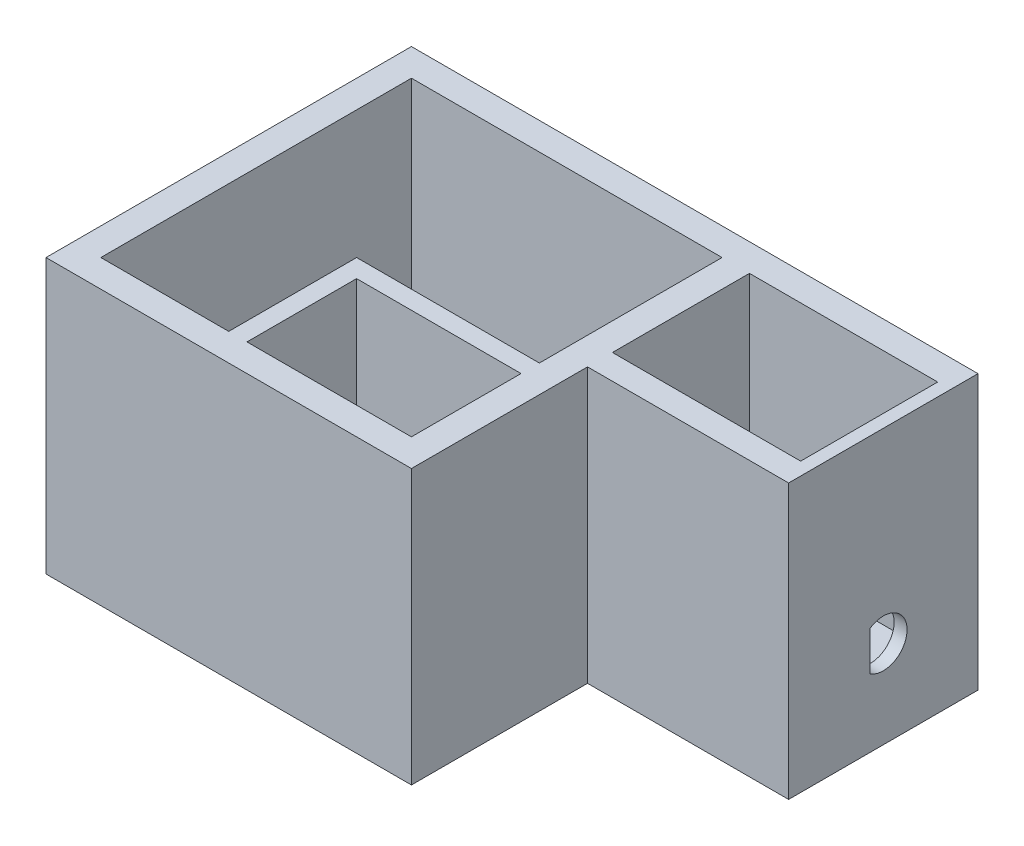
from build123d import *

# Parameters (mm, degrees)
CROQUIS2_W                 = 100
CROQUIS2_H                 = 100
SALIENTE_EXTRUIR1_DEPTH    = 75
CROQUIS3_W                 = 85
CROQUIS3_H                 = 85
CORTAR_EXTRUIR1_DEPTH      = 65
CROQUIS4_W                 = 50
CROQUIS4_H                 = 35
SALIENTE_EXTRUIR2_DEPTH    = 65
CROQUIS5_W                 = 45
CROQUIS5_H                 = 30
CORTAR_EXTRUIR2_DEPTH      = 1
CORTAR_EXTRUIR2_DEPTH_BACK = 65
CROQUIS6_W                 = 15
CROQUIS6_H                 = 10.846969935
CORTAR_EXTRUIR3_DEPTH      = 16
CROQUIS7_W                 = 28.617843409
CROQUIS7_H                 = 7.788560798
CORTAR_EXTRUIR4_DEPTH      = 11
CROQUIS8_W                 = 55.029985219
CROQUIS8_H                 = 51.821882126
SALIENTE_EXTRUIR3_DEPTH    = 75
CROQUIS9_W                 = 51.5
CROQUIS9_H                 = 37.5
CORTAR_EXTRUIR5_DEPTH      = 65
CROQUIS10_R                = 6.5
CORTAR_EXTRUIR6_DEPTH      = 43
CROQUIS11_W                = 5.616805414
CROQUIS11_H                = 14.360656008
SALIENTE_EXTRUIR9_DEPTH    = 3.5
CROQUIS12_W                = 15
CROQUIS12_H                = 15
CORTAR_EXTRUIR7_DEPTH      = 10


with BuildPart() as part:
    # Croquis2 → Saliente-Extruir1 (new body)
    with BuildSketch(Plane(origin=(0, 0, 0), x_dir=(1, 0, 0), z_dir=(0, 1, 0))):
        Rectangle(CROQUIS2_W, CROQUIS2_H)
    extrude(amount=SALIENTE_EXTRUIR1_DEPTH)

    # Croquis3 → Cortar-Extruir1 (cut)
    with BuildSketch(Plane(origin=(0, 75, 0), x_dir=(1, 0, 0), z_dir=(0, 1, 0))):
        Rectangle(CROQUIS3_W, CROQUIS3_H)
    extrude(amount=-CORTAR_EXTRUIR1_DEPTH, mode=Mode.SUBTRACT)

    # Croquis4 → Saliente-Extruir2 (add, through all)
    with BuildSketch(Plane(origin=(0, 10, 0), x_dir=(1, 0, 0), z_dir=(0, 1, 0))):
        with Locations((17.5, -25)):
            Rectangle(CROQUIS4_W, CROQUIS4_H)
    extrude(amount=SALIENTE_EXTRUIR2_DEPTH)

    # Croquis5 → Cortar-Extruir2 (cut, two sides)
    with BuildSketch(Plane(origin=(0, 75, 0), x_dir=(1, 0, 0), z_dir=(0, 1, 0))) as cortar_extruir2_sk:
        with Locations((19.989777708, -27.5)):
            Rectangle(CROQUIS5_W, CROQUIS5_H)
    extrude(amount=CORTAR_EXTRUIR2_DEPTH, mode=Mode.SUBTRACT)
    extrude(cortar_extruir2_sk.sketch, amount=-CORTAR_EXTRUIR2_DEPTH_BACK, mode=Mode.SUBTRACT)

    # Croquis6 → Cortar-Extruir3 (cut)
    with BuildSketch(Plane(origin=(-2.510222292, 0, 0), x_dir=(0, 0, -1), z_dir=(1, 0, 0))):
        with Locations((-35, 15.423484968)):
            Rectangle(CROQUIS6_W, CROQUIS6_H)
    extrude(amount=-CORTAR_EXTRUIR3_DEPTH, mode=Mode.SUBTRACT)

    # Croquis7 → Cortar-Extruir4 (cut)
    with BuildSketch(Plane(origin=(50, 0, 0), x_dir=(0, 0, -1), z_dir=(1, 0, 0))):
        with Locations((14.308921705, 13.894280399)):
            Rectangle(CROQUIS7_W, CROQUIS7_H)
    extrude(amount=-CORTAR_EXTRUIR4_DEPTH, mode=Mode.SUBTRACT)

    # Croquis8 → Saliente-Extruir3 (add, through all)
    with BuildSketch(Plane.XZ):
        with Locations((77.51499261, -24.089058937)):
            Rectangle(CROQUIS8_W, CROQUIS8_H)
    extrude(amount=-SALIENTE_EXTRUIR3_DEPTH)

    # Croquis9 → Cortar-Extruir5 (cut)
    with BuildSketch(Plane(origin=(0, 75, 0), x_dir=(1, 0, 0), z_dir=(0, 1, 0))):
        with Locations((75.75, 23.75)):
            Rectangle(CROQUIS9_W, CROQUIS9_H)
    extrude(amount=-CORTAR_EXTRUIR5_DEPTH, mode=Mode.SUBTRACT)

    # Croquis10 → Cortar-Extruir6 (cut)
    with BuildSketch(Plane(origin=(105.029985219, 0, 0), x_dir=(0, 0, -1), z_dir=(1, 0, 0))):
        with Locations((24.089058937, 24.029815949)):
            Circle(CROQUIS10_R)
    extrude(amount=-CORTAR_EXTRUIR6_DEPTH, mode=Mode.SUBTRACT)

    # Croquis11 → Saliente-Extruir9 (add)
    with BuildSketch(Plane(origin=(105.029985219, 0, 0), x_dir=(0, 0, -1), z_dir=(1, 0, 0))):
        with Locations((17.589058937, 24.029815949)):
            Rectangle(CROQUIS11_W, CROQUIS11_H)
    extrude(amount=-SALIENTE_EXTRUIR9_DEPTH)

    # Croquis12 → Cortar-Extruir7 (cut)
    with BuildSketch(Plane.XY.offset(-42.5)):
        with Locations((-35, 17.5)):
            Rectangle(CROQUIS12_W, CROQUIS12_H)
    extrude(amount=-CORTAR_EXTRUIR7_DEPTH, mode=Mode.SUBTRACT)


solid = part.part
